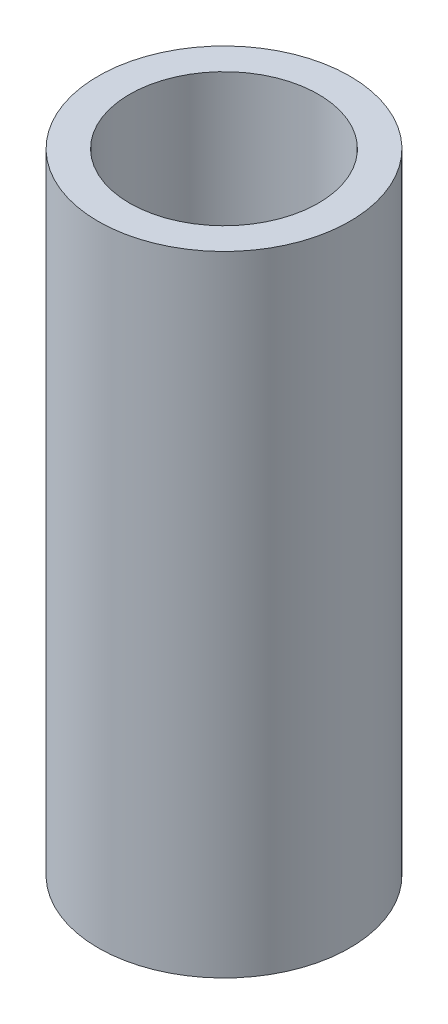
from build123d import *

# Parameters (mm, degrees)
SKETCH1_R           = 12.7
SKETCH1_R_2         = 9.525
BOSS_EXTRUDE1_DEPTH = 63.5


with BuildPart() as part:
    # Sketch1 → Boss-Extrude1 (new body)
    with BuildSketch(Plane(origin=(0, 0, 0), x_dir=(1, 0, 0), z_dir=(0, 1, 0))):
        Circle(SKETCH1_R)
        Circle(SKETCH1_R_2, mode=Mode.SUBTRACT)
    extrude(amount=BOSS_EXTRUDE1_DEPTH)


solid = part.part
